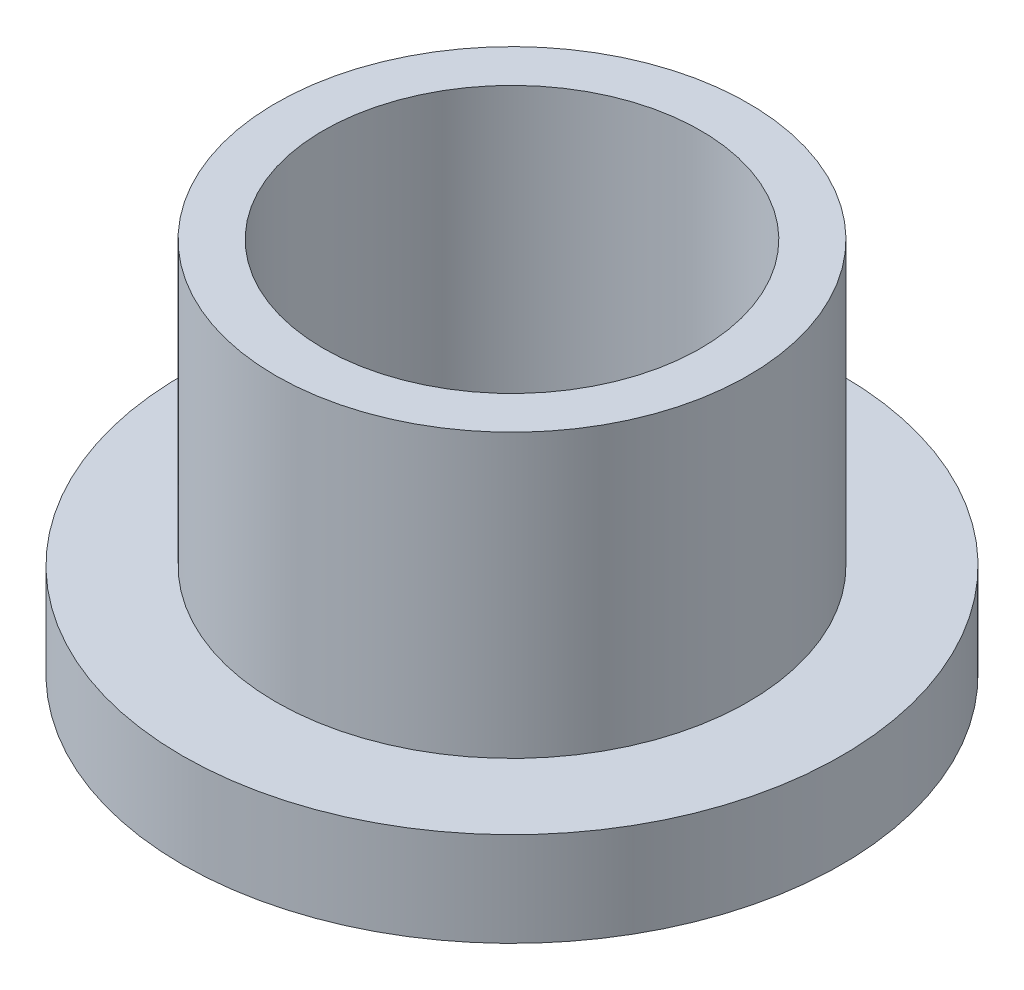
from build123d import *

# Parameters (mm, degrees)
SKETCH2_R           = 7.9629
SKETCH2_R_2         = 6.3627
BOSS_EXTRUDE1_DEPTH = 12.7
SKETCH3_R           = 11.1125
SKETCH3_R_2         = 7.9629
BOSS_EXTRUDE2_DEPTH = 3.175


with BuildPart() as part:
    # Sketch2 → Boss-Extrude1 (new body)
    with BuildSketch(Plane(origin=(0, 0, 0), x_dir=(1, 0, 0), z_dir=(0, 1, 0))):
        Circle(SKETCH2_R)
        Circle(SKETCH2_R_2, mode=Mode.SUBTRACT)
    extrude(amount=BOSS_EXTRUDE1_DEPTH)

    # Sketch3 → Boss-Extrude2 (add)
    with BuildSketch(Plane(origin=(0, 0, 0), x_dir=(1, 0, 0), z_dir=(0, 1, 0))):
        Circle(SKETCH3_R)
        Circle(SKETCH3_R_2, mode=Mode.SUBTRACT)
    extrude(amount=BOSS_EXTRUDE2_DEPTH)


solid = part.part
